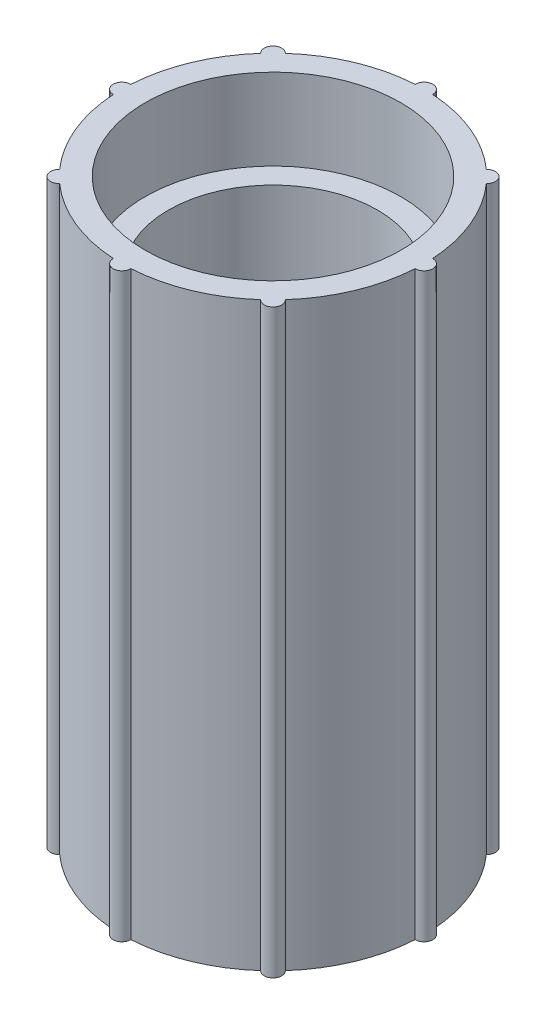
from build123d import *

# Parameters (mm, degrees)
ESQUISSE2_R                  = 13
BOSS_EXTRU_1_DEPTH           = 25
ESQUISSE3_R                  = 9
ENL_V_MAT_EXTRU_1_DEPTH      = 32.032241298
ESQUISSE4_R                  = 11
ENL_V_MAT_EXTRU_2_DEPTH      = 7
ESQUISSE6_R                  = 0.75
BOSS_EXTRU_2_DEPTH           = 25
R_P_TITION_CIRCULAIRE1_COUNT = 8
SYM_TRIE2_COPY_1_SKETCH_R    = 0.75
SYM_TRIE2_COPY_1_DEPTH       = 25
SYM_TRIE2_COPY_2_SKETCH_R    = 0.75
SYM_TRIE2_COPY_2_DEPTH       = 25
SYM_TRIE2_COPY_3_SKETCH_R    = 0.75
SYM_TRIE2_COPY_3_DEPTH       = 25
SYM_TRIE2_COPY_4_SKETCH_R    = 0.75
SYM_TRIE2_COPY_4_DEPTH       = 25
SYM_TRIE2_COPY_5_SKETCH_R    = 0.75
SYM_TRIE2_COPY_5_DEPTH       = 25
SYM_TRIE2_COPY_6_SKETCH_R    = 0.75
SYM_TRIE2_COPY_6_DEPTH       = 25
SYM_TRIE2_COPY_7_SKETCH_R    = 0.75
SYM_TRIE2_COPY_7_DEPTH       = 25


with BuildPart() as part:
    # Esquisse2 → Boss.-Extru.1 (new body)
    with BuildSketch(Plane(origin=(0, 0, 0), x_dir=(1, 0, 0), z_dir=(0, 1, 0))):
        with Locations(Location((0, 0, 0), (0, 0, 270))):
            Circle(ESQUISSE2_R)
    boss_extru_1 = extrude(amount=BOSS_EXTRU_1_DEPTH)

    # Esquisse3 → Enlèv. mat.-Extru.1 (cut, through all)
    with BuildSketch(Plane.XZ):
        with Locations(Location((0, 0, 0), (0, 0, 270))):
            Circle(ESQUISSE3_R)
    enl_v_mat_extru_1 = extrude(amount=-ENL_V_MAT_EXTRU_1_DEPTH, mode=Mode.SUBTRACT)

    # Esquisse4 → Enlèv. mat.-Extru.2 (cut)
    with BuildSketch(Plane.XZ):
        with Locations(Location((0, 0, 0), (0, 0, 270))):
            Circle(ESQUISSE4_R)
    enl_v_mat_extru_2 = extrude(amount=-ENL_V_MAT_EXTRU_2_DEPTH, mode=Mode.SUBTRACT)

    # Esquisse6 → Boss.-Extru.2 (add)
    with BuildSketch(Plane(origin=(0, 0, 0), x_dir=(-1, 0, 0), z_dir=(0, -1, 0))):
        with Locations((-13, 0)):
            Circle(ESQUISSE6_R)
    boss_extru_2 = extrude(amount=-BOSS_EXTRU_2_DEPTH)

    # Répétition circulaire1: Boss.-Extru.2 ×8 about axis
    r_p_tition_circulaire1_axis = Axis((0, 0, 0), (0, 1, 0))
    for i in range(1, R_P_TITION_CIRCULAIRE1_COUNT):
        add(boss_extru_2.rotate(r_p_tition_circulaire1_axis, i * 360 / R_P_TITION_CIRCULAIRE1_COUNT))

    # Symétrie2: Boss.-Extru.1, Enlèv. mat.-Extru.1, Enlèv. mat.-Extru.2, Boss.-Extru.2 across plane
    add(boss_extru_1.mirror(Plane.ZX.offset(25)))
    add(enl_v_mat_extru_1.mirror(Plane.ZX.offset(25)), mode=Mode.SUBTRACT)
    add(enl_v_mat_extru_2.mirror(Plane.ZX.offset(25)), mode=Mode.SUBTRACT)
    add(boss_extru_2.mirror(Plane.ZX.offset(25)))

    # Symétrie2 copy 1 sketch → Symétrie2 copy 1 (add)
    with BuildSketch(Plane(origin=(0, 50, 0), x_dir=(-0.7071067811865476, 0, 0.7071067811865475), z_dir=(0, 1, 0))):
        with Locations((-13, 0)):
            Circle(SYM_TRIE2_COPY_1_SKETCH_R)
    extrude(amount=-SYM_TRIE2_COPY_1_DEPTH)

    # Symétrie2 copy 2 sketch → Symétrie2 copy 2 (add)
    with BuildSketch(Plane.ZX.offset(50)):
        with Locations((-13, 0)):
            Circle(SYM_TRIE2_COPY_2_SKETCH_R)
    extrude(amount=-SYM_TRIE2_COPY_2_DEPTH)

    # Symétrie2 copy 3 sketch → Symétrie2 copy 3 (add)
    with BuildSketch(Plane(origin=(0, 50, 0), x_dir=(0.7071067811865475, 0, 0.7071067811865476), z_dir=(0, 1, 0))):
        with Locations((-13, 0)):
            Circle(SYM_TRIE2_COPY_3_SKETCH_R)
    extrude(amount=-SYM_TRIE2_COPY_3_DEPTH)

    # Symétrie2 copy 4 sketch → Symétrie2 copy 4 (add)
    with BuildSketch(Plane(origin=(0, 50, 0), x_dir=(1, 0, 0), z_dir=(0, 1, 0))):
        with Locations((-13, 0)):
            Circle(SYM_TRIE2_COPY_4_SKETCH_R)
    extrude(amount=-SYM_TRIE2_COPY_4_DEPTH)

    # Symétrie2 copy 5 sketch → Symétrie2 copy 5 (add)
    with BuildSketch(Plane(origin=(0, 50, 0), x_dir=(0.7071067811865477, 0, -0.7071067811865475), z_dir=(0, 1, 0))):
        with Locations((-13, 0)):
            Circle(SYM_TRIE2_COPY_5_SKETCH_R)
    extrude(amount=-SYM_TRIE2_COPY_5_DEPTH)

    # Symétrie2 copy 6 sketch → Symétrie2 copy 6 (add)
    with BuildSketch(Plane(origin=(0, 50, 0), x_dir=(0, 0, -1), z_dir=(0, 1, 0))):
        with Locations((-13, 0)):
            Circle(SYM_TRIE2_COPY_6_SKETCH_R)
    extrude(amount=-SYM_TRIE2_COPY_6_DEPTH)

    # Symétrie2 copy 7 sketch → Symétrie2 copy 7 (add)
    with BuildSketch(Plane(origin=(0, 50, 0), x_dir=(-0.7071067811865474, 0, -0.7071067811865477), z_dir=(0, 1, 0))):
        with Locations((-13, 0)):
            Circle(SYM_TRIE2_COPY_7_SKETCH_R)
    extrude(amount=-SYM_TRIE2_COPY_7_DEPTH)


solid = part.part
